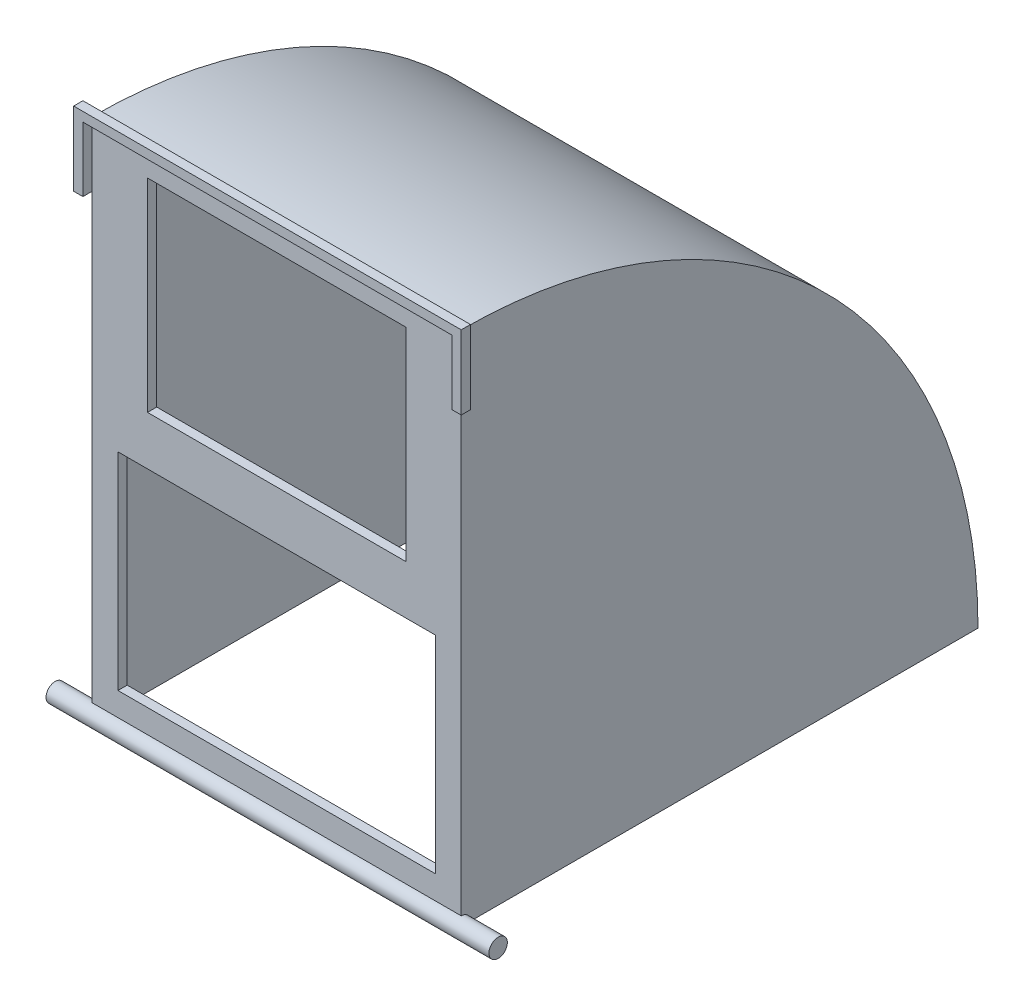
from build123d import *

# Parameters (mm, degrees)
BOSS_EXTRUDE1_DEPTH      = 127
BOSS_EXTRUDE2_DEPTH      = 3.175
SKETCH4_R                = 3.175
BOSS_EXTRUDE7_DEPTH      = 12.7
BOSS_EXTRUDE7_DEPTH_BACK = 139.7
SKETCH5_W                = 88.9
SKETCH5_H                = 69.85
SKETCH5_W_2              = 109.22
SKETCH5_H_2              = 71.12
CUT_EXTRUDE2_DEPTH       = 5.08
CUT_EXTRUDE3_DEPTH       = 127
SKETCH7_W                = 120.65
SKETCH7_H                = 168.275
CUT_EXTRUDE4_DEPTH       = 3.175
BOSS_EXTRUDE9_DEPTH      = 3.175
BOSS_EXTRUDE10_DEPTH     = 3.175


with BuildPart() as part:
    # Sketch1 → Boss-Extrude1 (new body)
    with BuildSketch(Plane(origin=(0, 0, 0), x_dir=(0, 0, -1), z_dir=(1, 0, 0))):
        with BuildLine():
            Line((0, 0), (0, 177.8))
            ThreePointArc((0, 177.8), (125.723585695, 125.723585695), (177.8, 0))
            Line((177.8, 0), (0, 0))
        make_face()
    extrude(amount=BOSS_EXTRUDE1_DEPTH)

    # Sketch4 → Boss-Extrude7 (add, two sides)
    with BuildSketch(Plane(origin=(127, 0, 0), x_dir=(0, 0, -1), z_dir=(1, 0, 0))) as boss_extrude7_sk:
        Circle(SKETCH4_R)
    extrude(amount=BOSS_EXTRUDE7_DEPTH)
    extrude(boss_extrude7_sk.sketch, amount=-BOSS_EXTRUDE7_DEPTH_BACK)

    # Sketch5 → Cut-Extrude2 (cut)
    with BuildSketch(Plane.XY):
        with Locations((63.5, 134.14375)):
            Rectangle(SKETCH5_W, SKETCH5_H)
        with Locations((63.5, 46.83125)):
            Rectangle(SKETCH5_W_2, SKETCH5_H_2)
    extrude(amount=-CUT_EXTRUDE2_DEPTH, mode=Mode.SUBTRACT)

    # Sketch6 → Cut-Extrude3 (cut)
    with BuildSketch(Plane.ZY):
        with BuildLine():
            Line((-3.175, 3.175), (-174.596133978, 3.175))
            ThreePointArc((-174.596133978, 3.175), (-123.478521665, 123.478521665), (-3.175, 174.596133978))
            Line((-3.175, 174.596133978), (-3.175, 3.175))
        make_face()
    extrude(amount=-CUT_EXTRUDE3_DEPTH, mode=Mode.SUBTRACT)

    # Sketch7 → Cut-Extrude4 (cut)
    with BuildSketch(Plane.XZ):
        with Locations((63.5, -90.4875)):
            Rectangle(SKETCH7_W, SKETCH7_H)
    extrude(amount=-CUT_EXTRUDE4_DEPTH, mode=Mode.SUBTRACT)

    # Sketch8 → Boss-Extrude9 (add)
    with BuildSketch(Plane.ZY):
        with BuildLine():
            Line((-176.525431596, 1.27), (-4.259709497, 1.27))
            ThreePointArc((-4.259709497, 1.27), (-3.143089642, 3.143089642), (-1.27, 4.259709497))
            Line((-1.27, 4.259709497), (-1.27, 176.525431596))
            ThreePointArc((-1.27, 176.525431596), (-124.825560083, 124.825560083), (-176.525431596, 1.27))
        make_face()
    extrude(amount=-BOSS_EXTRUDE9_DEPTH)

    # Sketch9 → Boss-Extrude10 (add)
    with BuildSketch(Plane(origin=(127, 0, 0), x_dir=(0, 0, -1), z_dir=(1, 0, 0))):
        with BuildLine():
            Line((4.259709497, 1.27), (176.525431596, 1.27))
            ThreePointArc((176.525431596, 1.27), (124.825560083, 124.825560083), (1.27, 176.525431596))
            Line((1.27, 176.525431596), (1.27, 4.259709497))
            ThreePointArc((1.27, 4.259709497), (3.143089642, 3.143089642), (4.259709497, 1.27))
        make_face()
    extrude(amount=-BOSS_EXTRUDE10_DEPTH)


with BuildPart() as body_2:
    # Sketch2 → Boss-Extrude2 (new body)
    with BuildSketch(Plane.XY):
        Polygon((0, 155.575), (-3.175, 155.575), (-3.175, 180.975), (130.175, 180.975), (130.175, 155.575), (127, 155.575), (127, 177.8), (0, 177.8), align=None)
    extrude(amount=BOSS_EXTRUDE2_DEPTH)


solid = Compound([part.part, body_2.part])
